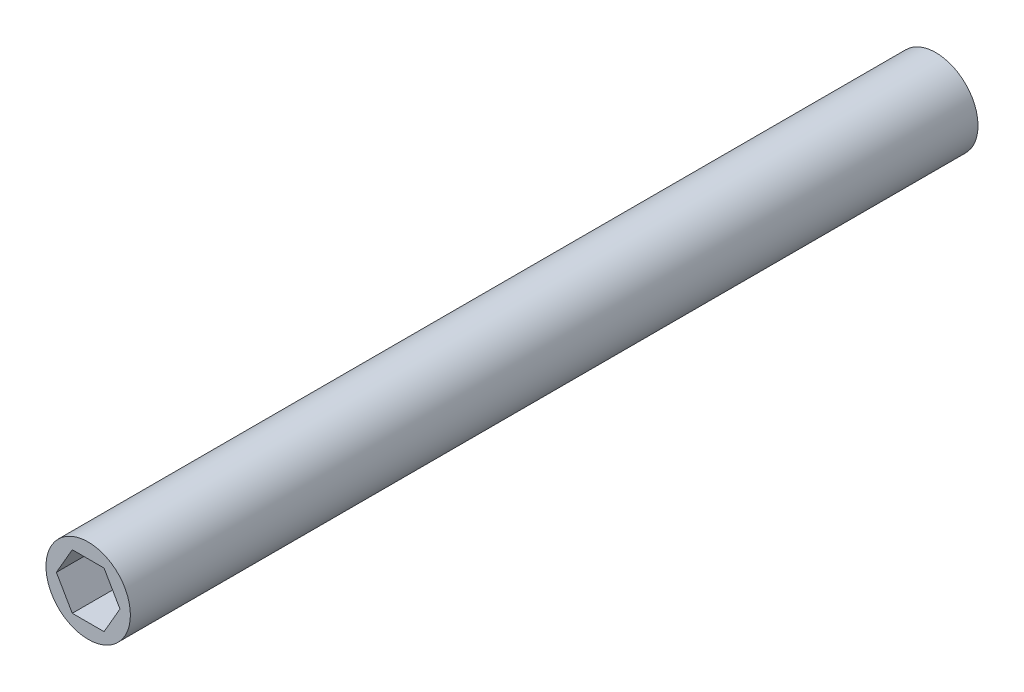
from build123d import *

# Parameters (mm, degrees)
SKETCH8_R           = 6.3246
BOSS_EXTRUDE7_DEPTH = 127
SKETCH9_W           = 3.175
SKETCH9_H           = 1.6002
BOSS_EXTRUDE8_DEPTH = 49.911
SKETCH10_W          = 21.336
SKETCH10_H          = 1.002575458
CUT_EXTRUDE1_DEPTH  = 3.937
CUT_EXTRUDE2_DEPTH  = 8.89


with BuildPart() as part:
    # Sketch8 → Boss-Extrude7 (new body)
    with BuildSketch(Plane.XY):
        Circle(SKETCH8_R)
    extrude(amount=BOSS_EXTRUDE7_DEPTH)

    # Sketch9 → Boss-Extrude8 (add)
    with BuildSketch(Plane.XY):
        with Locations((0, -6.3246)):
            Rectangle(SKETCH9_W, SKETCH9_H)
    extrude(amount=BOSS_EXTRUDE8_DEPTH)

    # Sketch10 → Cut-Extrude1 (cut)
    with BuildSketch(Plane.ZY.offset(1.5875)):
        with Locations((10.668, -6.623412271)):
            Rectangle(SKETCH10_W, SKETCH10_H)
    extrude(amount=-CUT_EXTRUDE1_DEPTH, mode=Mode.SUBTRACT)

    # Sketch11 → Cut-Extrude2 (cut)
    with BuildSketch(Plane.XY.offset(127)):
        Polygon((4.7625, 0), (2.38125, 4.124445986), (-2.38125, 4.124445986), (-4.7625, 0), (-2.38125, -4.124445986), (2.38125, -4.124445986), align=None)
    extrude(amount=-CUT_EXTRUDE2_DEPTH, mode=Mode.SUBTRACT)


solid = part.part
